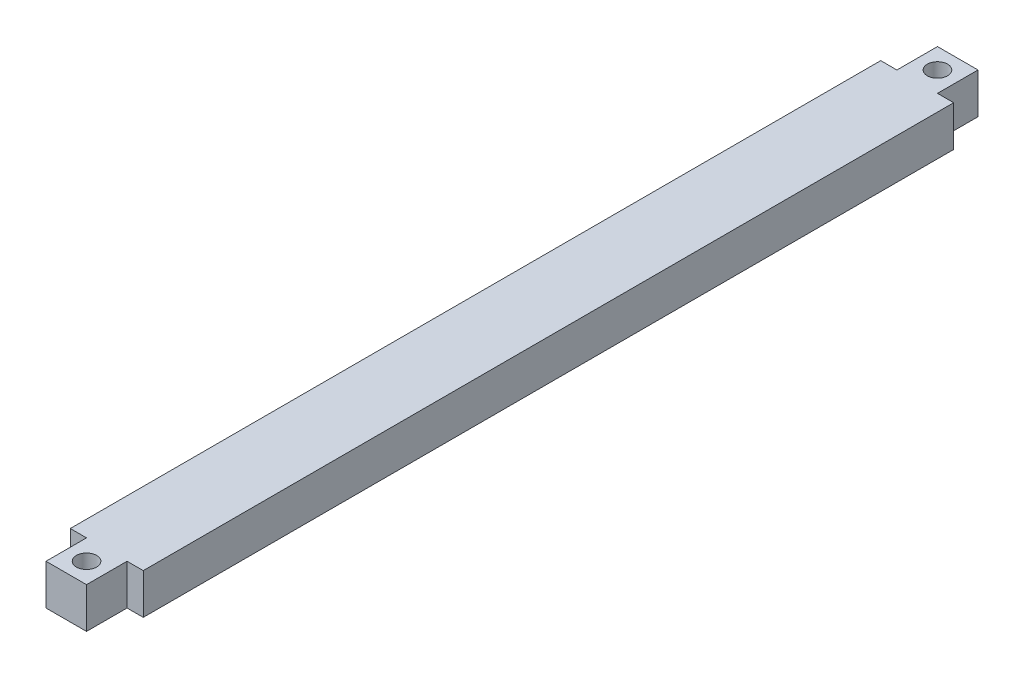
from build123d import *

# Parameters (mm, degrees)
SKETCH1_W           = 5
SKETCH1_H           = 5
BOSS_EXTRUDE1_DEPTH = 110
SKETCH2_W           = 2
SKETCH2_H           = 100
BOSS_EXTRUDE2_DEPTH = 5
BOSS_EXTRUDE3_DEPTH = 5


with BuildPart() as part:
    # Sketch1 → Boss-Extrude1 (new body)
    with BuildSketch(Plane.XY):
        with Locations((2.938510718, -1.487078427)):
            Rectangle(SKETCH1_W, SKETCH1_H)
    extrude(amount=BOSS_EXTRUDE1_DEPTH)

    # Sketch2 → Boss-Extrude2 (add)
    with BuildSketch(Plane(origin=(0, 1.012921573, 0), x_dir=(1, 0, 0), z_dir=(0, 1, 0))):
        with Locations((6.438510718, -55)):
            Rectangle(SKETCH2_W, SKETCH2_H)
    extrude(amount=-BOSS_EXTRUDE2_DEPTH)

    # Sketch3 → Boss-Extrude3 (add)
    with BuildSketch(Plane(origin=(0, 1.012921573, 0), x_dir=(1, 0, 0), z_dir=(0, 1, 0))):
        Polygon((0.438510718, -5.009089169), (-1.561489282, -5), (-1.561489282, -105), (0.438510718, -105), align=None)
    extrude(amount=-BOSS_EXTRUDE3_DEPTH)

    # Sketch6 → M3 Tapped Hole1 (revolve, cut)
    with BuildSketch(Plane(origin=(2.938510718, 1.012921573, 2.502272292), x_dir=(0, 0, 1), z_dir=(1, 0, 0))):
        Polygon((0, 0), (0, 8.751075774), (1.25, 8), (1.25, 0), align=None)
    m3_tapped_hole1 = revolve(axis=Axis((2.938510718, 7.362921573, 2.502272292), (0, -1, 0)), mode=Mode.SUBTRACT)

    # Mirror1: M3 Tapped Hole1 across plane
    add(m3_tapped_hole1.mirror(Plane(origin=(0, 0, 55), x_dir=(1, 0, 0), z_dir=(0, 0, -1))), mode=Mode.SUBTRACT)


solid = part.part
